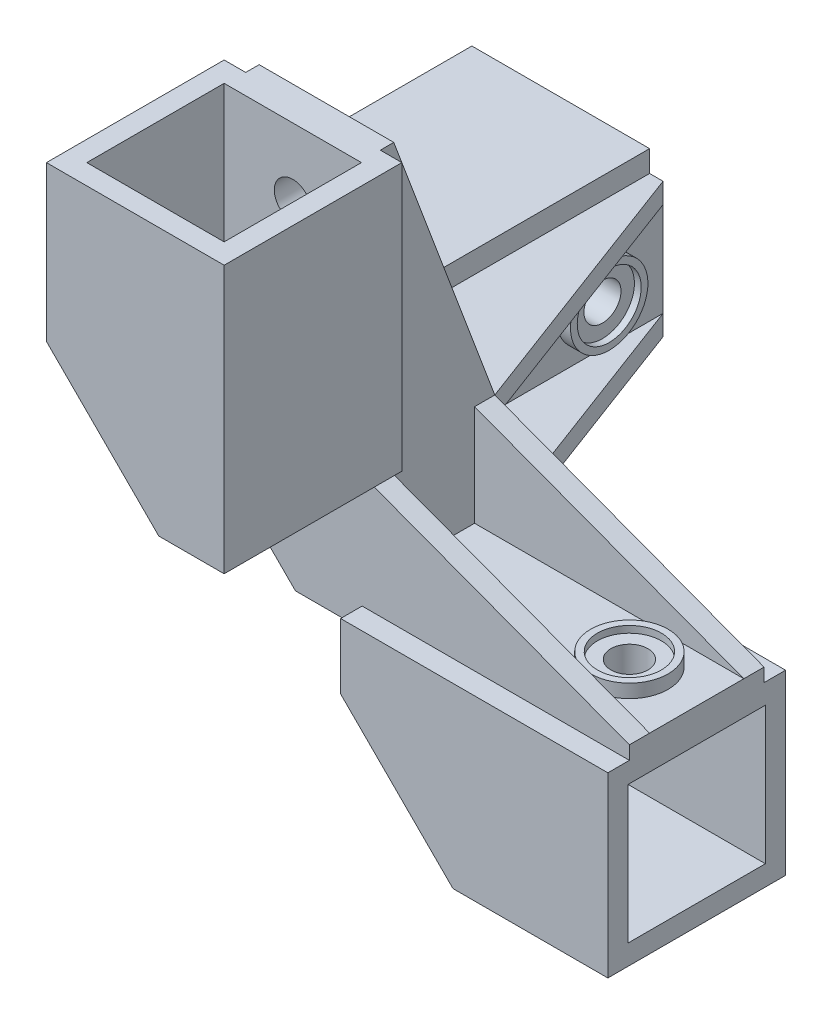
from build123d import *

# Parameters (mm, degrees)
SKETCH1_W           = 20
SKETCH1_H           = 20
BOSS_EXTRUDE1_DEPTH = 20
SKETCH2_W           = 40
SKETCH2_H           = 20
BOSS_EXTRUDE2_DEPTH = 5
BOSS_EXTRUDE3_DEPTH = 3
BOSS_EXTRUDE4_START = -20
BOSS_EXTRUDE4_DEPTH = 3
SKETCH4_R           = 4.75
SKETCH4_R_2         = 2.75
BOSS_EXTRUDE5_DEPTH = 1
SKETCH4_3_R         = 2.75
CUT_EXTRUDE1_DEPTH  = 66
SKETCH4_4_R         = 5.75
SKETCH4_4_R_2       = 4.75
BOSS_EXTRUDE6_DEPTH = 2
BOSS_EXTRUDE7_START = -20.3
BOSS_EXTRUDE7_DEPTH = 39.7
CIRPATTERN1_COUNT   = 3


with BuildPart() as part:
    # Sketch1 → Boss-Extrude1 (new body)
    with BuildSketch(Plane(origin=(0, 0, 0), x_dir=(1, 0, 0), z_dir=(0, 1, 0))):
        with Locations((10, 10)):
            Rectangle(SKETCH1_W, SKETCH1_H)
    extrude(amount=BOSS_EXTRUDE1_DEPTH)

    # Sketch2 → Boss-Extrude2 (add)
    with BuildSketch(Plane(origin=(0, 0, 0), x_dir=(1, 0, 0), z_dir=(0, 1, 0))):
        with Locations((40, 10)):
            Rectangle(SKETCH2_W, SKETCH2_H)
    boss_extrude2 = extrude(amount=BOSS_EXTRUDE2_DEPTH)

    # Sketch3 → Boss-Extrude3 (add)
    with BuildSketch(Plane.XY):
        Polygon((20, 5), (20, 20), (60, 5), align=None)
    boss_extrude3 = extrude(amount=-BOSS_EXTRUDE3_DEPTH)

    # Sketch3_2 → Boss-Extrude4 (add)
    with BuildSketch(Plane.XY.offset(BOSS_EXTRUDE4_START)):
        Polygon((20, 5), (20, 20), (60, 5), align=None)
    boss_extrude4 = extrude(amount=BOSS_EXTRUDE4_DEPTH)

    # Sketch4 → Boss-Extrude5 (add)
    with BuildSketch(Plane(origin=(0, 5, 0), x_dir=(1, 0, 0), z_dir=(0, 1, 0))):
        with Locations(Location((50, 10, 0), (0, 0, 90))):
            Circle(SKETCH4_R)
        with Locations(Location((50, 10, 0), (0, 0, 270))):
            Circle(SKETCH4_R_2, mode=Mode.SUBTRACT)
    boss_extrude5 = extrude(amount=BOSS_EXTRUDE5_DEPTH)

    # Sketch4_3 → Cut-Extrude1 (cut, through all)
    with BuildSketch(Plane(origin=(0, 5, 0), x_dir=(1, 0, 0), z_dir=(0, 1, 0))):
        with Locations(Location((50, 10, 0), (0, 0, 270))):
            Circle(SKETCH4_3_R)
    cut_extrude1 = extrude(amount=-CUT_EXTRUDE1_DEPTH, mode=Mode.SUBTRACT)

    # Sketch4_4 → Boss-Extrude6 (add)
    with BuildSketch(Plane(origin=(0, 5, 0), x_dir=(1, 0, 0), z_dir=(0, 1, 0))):
        with Locations(Location((50, 10, 0), (0, 0, 90))):
            Circle(SKETCH4_4_R)
        with Locations(Location((50, 10, 0), (0, 0, 270))):
            Circle(SKETCH4_4_R_2, mode=Mode.SUBTRACT)
    boss_extrude6 = extrude(amount=BOSS_EXTRUDE6_DEPTH)

    # Sketch5 → Boss-Extrude7 (add)
    with BuildSketch(Plane.ZY.offset(BOSS_EXTRUDE7_START)):
        Polygon((-20.2, -20.4), (-20.2, 0), (-20, 0), (-20, 3), (-23.2, 3), (-23.2, -23.4), (3.2, -23.4), (3.2, 3), (0, 3), (0, 0), (0.2, 0), (0.2, -20.4), align=None)
    boss_extrude7 = extrude(amount=-BOSS_EXTRUDE7_DEPTH)

    # CirPattern1: Boss-Extrude2, Boss-Extrude3, Boss-Extrude4, Boss-Extrude5, Cut-Extrude1, Boss-Extrude6, Boss-Extrude7 ×3 about axis
    cirpattern1_axis = Axis((0, 0, 0), (0.5773502691896256, 0.5773502691896258, -0.5773502691896258))
    add([boss_extrude2.rotate(cirpattern1_axis, i * 360 / CIRPATTERN1_COUNT) for i in range(1, CIRPATTERN1_COUNT)])
    add([boss_extrude3.rotate(cirpattern1_axis, i * 360 / CIRPATTERN1_COUNT) for i in range(1, CIRPATTERN1_COUNT)])
    add([boss_extrude4.rotate(cirpattern1_axis, i * 360 / CIRPATTERN1_COUNT) for i in range(1, CIRPATTERN1_COUNT)])
    add([boss_extrude5.rotate(cirpattern1_axis, i * 360 / CIRPATTERN1_COUNT) for i in range(1, CIRPATTERN1_COUNT)])
    add([cut_extrude1.rotate(cirpattern1_axis, i * 360 / CIRPATTERN1_COUNT) for i in range(1, CIRPATTERN1_COUNT)], mode=Mode.SUBTRACT)
    add([boss_extrude6.rotate(cirpattern1_axis, i * 360 / CIRPATTERN1_COUNT) for i in range(1, CIRPATTERN1_COUNT)])
    add([boss_extrude7.rotate(cirpattern1_axis, i * 360 / CIRPATTERN1_COUNT) for i in range(1, CIRPATTERN1_COUNT)])

    # SurfaceCut1
    split(bisect_by=Plane(origin=(3.464101615, 3.464101615, -3.464101615), x_dir=(0.8164965809277263, -0.40824829046386285, 0.40824829046386285), z_dir=(-0.5773502691896255, -0.5773502691896256, 0.5773502691896262)), keep=Keep.BOTTOM)


solid = part.part
